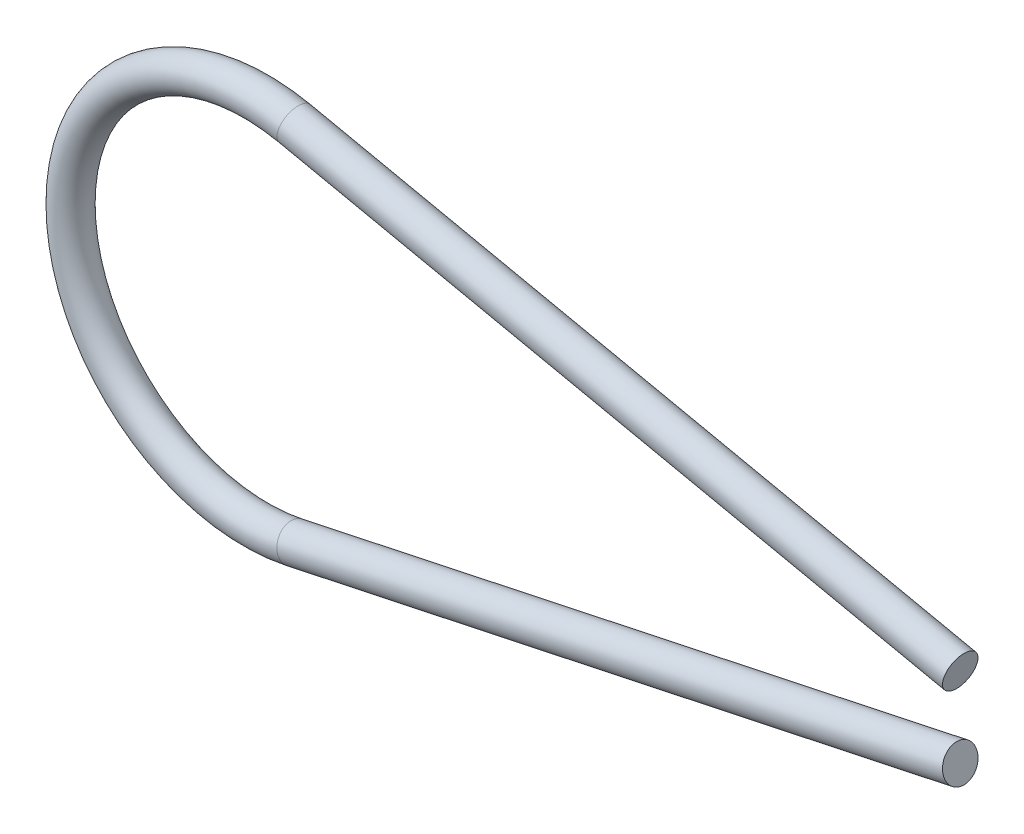
from build123d import *

# Parameters (mm, degrees)
SKETCH2_R = 0.15


with BuildPart() as part:
    # Sweep1: sweep along a curve in space
    with BuildLine() as sweep1_path:
        Line((6.074385122, 0.344594536, 0), (0.332658705, 1.565036161, 0))
        ThreePointArc((0.332658705, 1.565036161, 0), (-1.6, 0, 0), (0.332658705, -1.565036161, 0))
        Line((0.332658705, -1.565036161, 0), (6.074385122, -0.344594536, 0))
    # Sketch2 → Sweep1 (sweep)
    with BuildSketch(Plane(origin=(6.074385122, 0.344594536, 0), x_dir=(0, 0, 1), z_dir=(-0.978147601, 0.207911691, 0))):
        Circle(SKETCH2_R)
    sweep(path=sweep1_path.line)


solid = part.part
